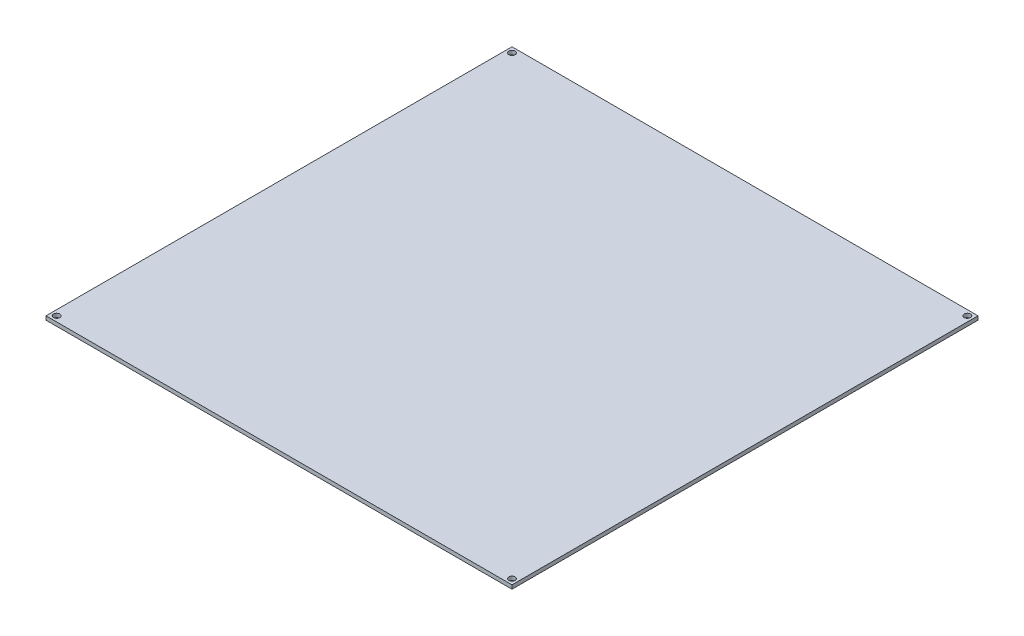
from build123d import *

# Parameters (mm, degrees)
SKETCH1_W           = 214
SKETCH1_H           = 214
SKETCH1_R           = 1.445
BOSS_EXTRUDE1_DEPTH = 1.75


with BuildPart() as part:
    # Sketch1 → Boss-Extrude1 (new body)
    with BuildSketch(Plane(origin=(0, 0, 0), x_dir=(1, 0, 0), z_dir=(0, 1, 0))):
        Rectangle(SKETCH1_W, SKETCH1_H)
        with Locations((-104.555, 104.555)):
            Circle(SKETCH1_R, mode=Mode.SUBTRACT)
        with Locations((104.555, 104.555)):
            Circle(SKETCH1_R, mode=Mode.SUBTRACT)
        with Locations((104.555, -104.555)):
            Circle(SKETCH1_R, mode=Mode.SUBTRACT)
        with Locations((-104.555, -104.555)):
            Circle(SKETCH1_R, mode=Mode.SUBTRACT)
    extrude(amount=BOSS_EXTRUDE1_DEPTH)


solid = part.part
